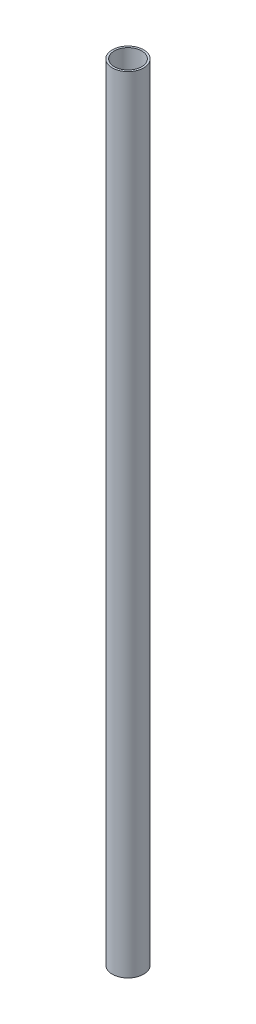
from build123d import *

# Parameters (mm, degrees)
SKETCH1_R           = 4
SKETCH1_R_2         = 3.5
BOSS_EXTRUDE1_DEPTH = 200


with BuildPart() as part:
    # Sketch1 → Boss-Extrude1 (new body)
    with BuildSketch(Plane(origin=(0, 0, 0), x_dir=(1, 0, 0), z_dir=(0, 1, 0))):
        Circle(SKETCH1_R)
        Circle(SKETCH1_R_2, mode=Mode.SUBTRACT)
    extrude(amount=BOSS_EXTRUDE1_DEPTH)


solid = part.part
